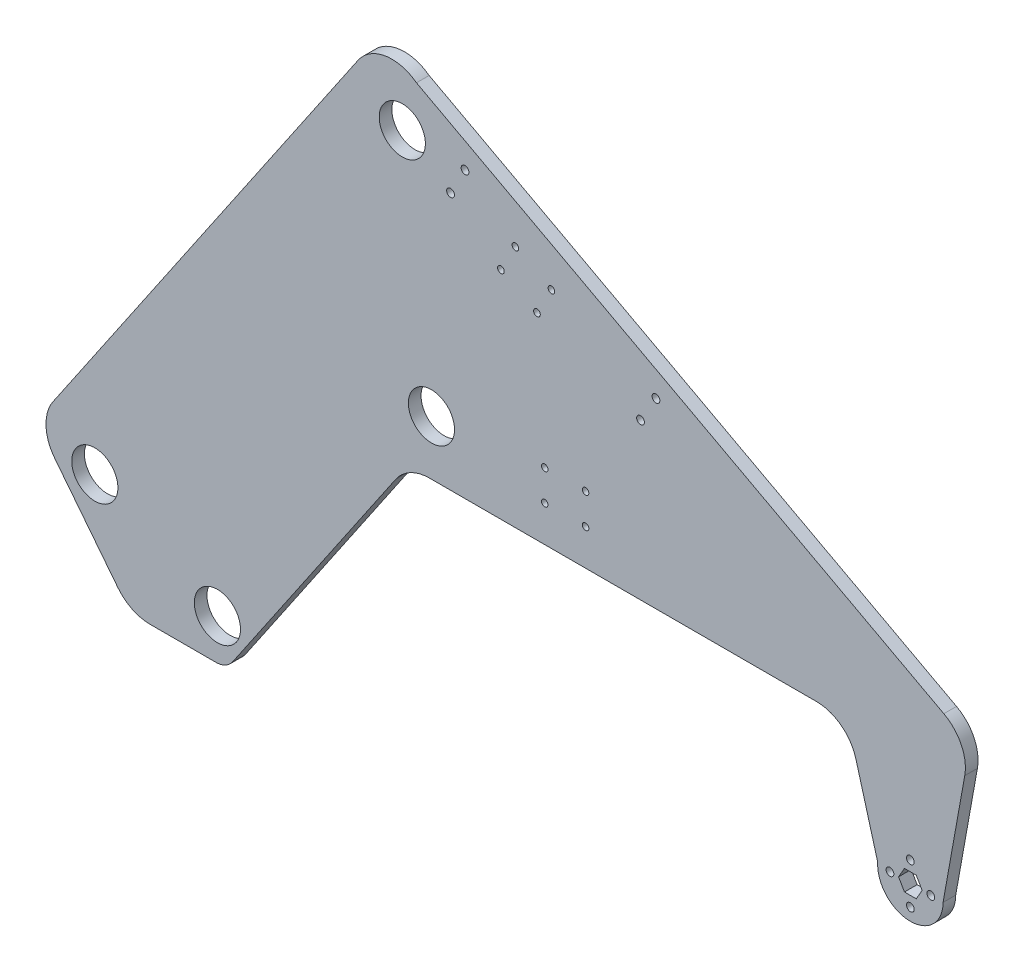
from build123d import *

# Parameters (mm, degrees)
MODEL_R             = 14.351
MODEL_R_2           = 2.413
BOSS_EXTRUDE1_DEPTH = 7.874
SKETCH17_R          = 2.0701
CUT_EXTRUDE1_DEPTH  = 8.874
SKETCH18_R          = 2.0193
CUT_EXTRUDE2_DEPTH  = 8.874


with BuildPart() as part:
    # Model → Boss-Extrude1 (new body)
    with BuildSketch(Plane.XY):
        with BuildLine():
            Line((127.809114586, 137.689660276), (-200.005250584, 313.419470721))
            ThreePointArc((-200.005250584, 313.419470721), (-219.438743814, 318.210854709), (-236.308771814, 307.439588539))
            Line((-236.308771814, 307.439588539), (-425.925316767, 28.829603592))
            ThreePointArc((-425.925316767, 28.829603592), (-430.312243104, 13.671313347), (-424.900993017, -1.152223962))
            Line((-424.900993017, -1.152223962), (-385.581467186, -51.204797614))
            ThreePointArc((-385.581467186, -51.204797614), (-376.711879358, -58.358090396), (-365.607528193, -60.913979882))
            Line((-365.607528193, -60.913979882), (-324.737451002, -60.913979882))
            ThreePointArc((-324.737451002, -60.913979882), (-318.798508014, -59.439796386), (-314.23831963, -55.359484793))
            Line((-314.23831963, -55.359484793), (-212.899365952, 93.541257838))
            ThreePointArc((-212.899365952, 93.541257838), (-203.778989185, 101.701881024), (-191.901103209, 104.650248016))
            Line((-191.901103209, 104.650248016), (48.661197018, 104.650248016))
            ThreePointArc((48.661197018, 104.650248016), (64.032332507, 99.471232012), (73.135172194, 86.046168785))
            Line((73.135172194, 86.046168785), (86.727013732, 37.098218434))
            ThreePointArc((86.727013732, 37.098218434), (106.362581421, 15.501750179), (127.326236921, 35.811553418))
            Line((127.326236921, 35.811553418), (140.807890588, 110.809453484))
            ThreePointArc((140.807890588, 110.809453484), (138.675228362, 126.361225539), (127.809114586, 137.689660276))
        make_face()
        with Locations((-323.775189267, -35.513979882)):
            Circle(MODEL_R, mode=Mode.SUBTRACT)
        with Locations((-399.975189267, 2.586020118)):
            Circle(MODEL_R, mode=Mode.SUBTRACT)
        with Locations((107.006236921, 23.111553418)):
            Circle(MODEL_R_2, mode=Mode.SUBTRACT)
        with Locations((94.306236921, 35.811553418)):
            Circle(MODEL_R_2, mode=Mode.SUBTRACT)
        Polygon((110.67241113, 42.161553418), (114.33858534, 35.811553418), (110.67241113, 29.461553418), (103.340062712, 29.461553418), (99.673888502, 35.811553418), (103.340062712, 42.161553418), (107.006236921, 42.161553418), align=None, mode=Mode.SUBTRACT)
        with Locations((119.706236921, 35.811553418)):
            Circle(MODEL_R_2, mode=Mode.SUBTRACT)
        with Locations((107.006236921, 48.511553418)):
            Circle(MODEL_R_2, mode=Mode.SUBTRACT)
        with Locations((-190.707148919, 138.516914683)):
            Circle(MODEL_R, mode=Mode.SUBTRACT)
        with Locations((-178.846696227, 264.756008796)):
            Circle(MODEL_R_2, mode=Mode.SUBTRACT)
        with Locations((-208.832932893, 283.437784316)):
            Circle(MODEL_R, mode=Mode.SUBTRACT)
        with Locations((-169.846303212, 281.545750473)):
            Circle(MODEL_R_2, mode=Mode.SUBTRACT)
        with Locations((-60.736830905, 201.457194342)):
            Circle(MODEL_R_2, mode=Mode.SUBTRACT)
        with Locations((-51.138479016, 217.912410568)):
            Circle(MODEL_R_2, mode=Mode.SUBTRACT)
    extrude(amount=BOSS_EXTRUDE1_DEPTH)

    # Sketch17 → Cut-Extrude1 (cut, through all)
    with BuildSketch(Plane(origin=(0, 0, 0), x_dir=(-1, 0, 0), z_dir=(0, 0, -1))):
        with Locations((138.53320591, 255.908211149)):
            Circle(SKETCH17_R)
        with Locations((147.519620664, 239.110983703)):
            Circle(SKETCH17_R)
        with Locations((125.123317403, 227.129097364)):
            Circle(SKETCH17_R)
        with Locations((116.136902649, 243.92632481)):
            Circle(SKETCH17_R)
    extrude(amount=-CUT_EXTRUDE1_DEPTH, mode=Mode.SUBTRACT)

    # Sketch18 → Cut-Extrude2 (cut, through all)
    with BuildSketch(Plane(origin=(0, 0, 0), x_dir=(-1, 0, 0), z_dir=(0, 0, -1))):
        with Locations((120.287453551, 146.062677987)):
            Circle(SKETCH18_R)
        with Locations((120.287453551, 127.012677987)):
            Circle(SKETCH18_R)
        with Locations((94.887453551, 127.012677987)):
            Circle(SKETCH18_R)
        with Locations((94.887453551, 146.062677987)):
            Circle(SKETCH18_R)
    extrude(amount=-CUT_EXTRUDE2_DEPTH, mode=Mode.SUBTRACT)


solid = part.part
